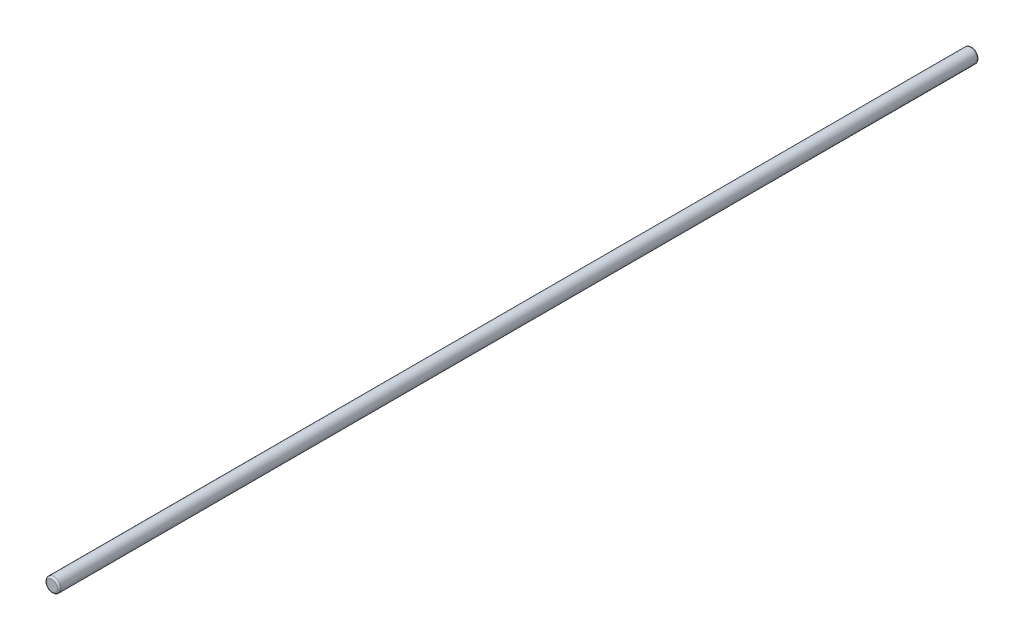
from build123d import *

# Parameters (mm, degrees)
SKETCH_1_R      = 4
EXTRUDE_1_DEPTH = 520
FILLET_1_R      = 1
FILLET_2_R      = 1


with BuildPart() as part:
    # ｽｹｯﾁ1 → ﾎﾞｽ - 押し出し1 (new body)
    with BuildSketch(Plane.XY):
        Circle(SKETCH_1_R)
    extrude(amount=EXTRUDE_1_DEPTH)

    # ﾌｨﾚｯﾄ1
    fillet_1_edges = [part.edges().sort_by_distance(p)[0] for p in [
        (-4, 0, 520),
    ]]
    fillet(fillet_1_edges, radius=FILLET_1_R)

    # ﾌｨﾚｯﾄ2
    fillet_2_edges = [part.edges().sort_by_distance(p)[0] for p in [
        (-4, 0, 0),
    ]]
    fillet(fillet_2_edges, radius=FILLET_2_R)


solid = part.part
